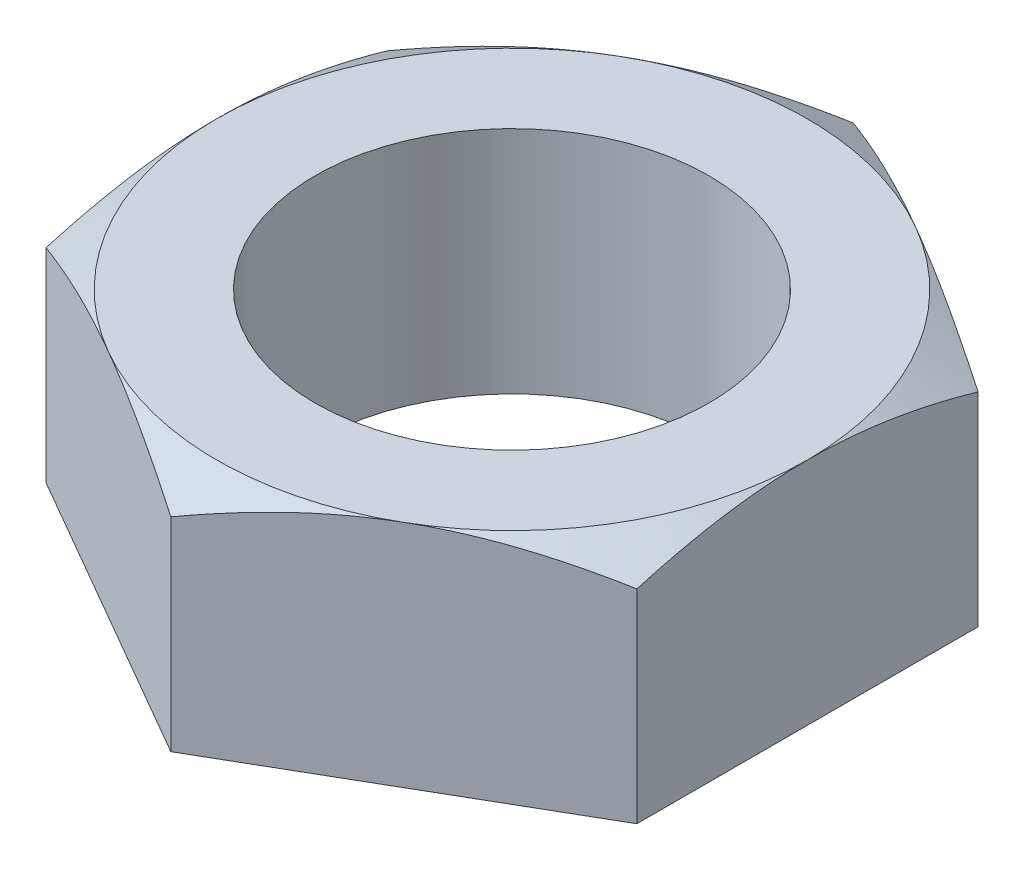
from build123d import *

# Parameters (mm, degrees)
SKETCH1_R           = 4.7625
BOSS_EXTRUDE1_DEPTH = 2.778125
SKETCH5_OUTSIDE_W   = 43.504
SKETCH5_OUTSIDE_H   = 45.714
SKETCH5_OUTSIDE_R   = 7.14375
CUT_EXTRUDE2_DEPTH  = 6.55625
CUT_EXTRUDE2_TAPER  = 60


with BuildPart() as part:
    # Sketch1 → Boss-Extrude1 (new body, symmetric)
    with BuildSketch(Plane(origin=(0, 0, 0), x_dir=(1, 0, 0), z_dir=(0, 1, 0))):
        Polygon((-7.14375, 4.124445986), (-7.14375, -4.124445986), (0, -8.248891971), (7.14375, -4.124445986), (7.14375, 4.124445986), (0, 8.248891971), align=None)
        Circle(SKETCH1_R, mode=Mode.SUBTRACT)
    extrude(amount=BOSS_EXTRUDE1_DEPTH, both=True)

    # Sketch5 outside → Cut-Extrude2 (cut, through all)
    with BuildSketch(Plane(origin=(0, 2.778125, 0), x_dir=(1, 0, 0), z_dir=(0, 1, 0))):
        Rectangle(SKETCH5_OUTSIDE_W, SKETCH5_OUTSIDE_H)
        Circle(SKETCH5_OUTSIDE_R, mode=Mode.SUBTRACT)
    extrude(amount=-CUT_EXTRUDE2_DEPTH, taper=CUT_EXTRUDE2_TAPER, mode=Mode.SUBTRACT)


solid = part.part
